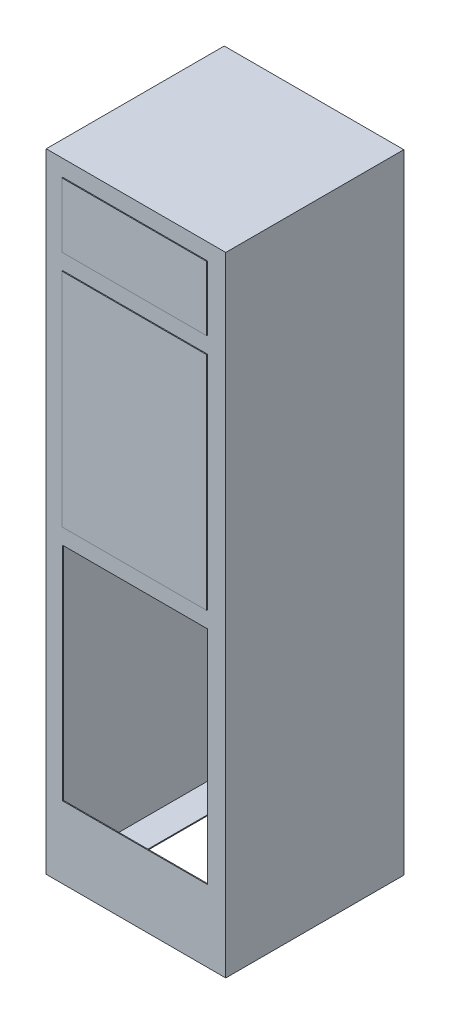
from build123d import *

# Parameters (mm, degrees)
CROQUIS1_W                = 600
CROQUIS1_H                = 2100
SALIENTE_EXTRUIR1_DEPTH   = 595
CROQUIS2_W                = 594
CROQUIS2_H                = 2094
CORTAR_EXTRUIR1_DEPTH     = 592
CROQUIS3_W                = 594
CROQUIS3_H                = 237
SALIENTE_EXTRUIR2_DEPTH   = 3
CROQUIS4_W                = 400
CROQUIS4_H                = 395
CORTAR_EXTRUIR2_DEPTH     = 3
CROQUIS5_W                = 52
CROQUIS5_H                = 740
SALIENTE_EXTRUIR3_DEPTH   = 3
CROQUIS5_W_2              = 58
SALIENTE_EXTRUIR3_2_DEPTH = 3
CROQUIS6_W                = 484
CROQUIS6_H                = 740
SALIENTE_EXTRUIR4_DEPTH   = 3
CROQUIS7_W                = 594
CROQUIS7_H                = 55
SALIENTE_EXTRUIR5_DEPTH   = 3
CROQUIS8_W                = 52
CROQUIS8_H                = 740
CROQUIS8_W_2              = 58
SALIENTE_EXTRUIR6_DEPTH   = 3
CROQUIS9_W                = 484
CROQUIS9_H                = 740
SALIENTE_EXTRUIR7_DEPTH   = 3
CROQUIS10_W               = 594
CROQUIS10_H               = 322
CROQUIS10_W_2             = 484
CROQUIS10_H_2             = 215
SALIENTE_EXTRUIR8_DEPTH   = 3
CROQUIS11_W               = 484
CROQUIS11_H               = 215
SALIENTE_EXTRUIR9_DEPTH   = 3
CROQUIS12_W               = 484
CROQUIS12_H               = 740
CORTAR_EXTRUIR3_DEPTH     = 4


with BuildPart() as part:
    # Croquis1 → Saliente-Extruir1 (new body)
    with BuildSketch(Plane.XY):
        Rectangle(CROQUIS1_W, CROQUIS1_H)
    extrude(amount=SALIENTE_EXTRUIR1_DEPTH)

    # Croquis2 → Cortar-Extruir1 (cut)
    with BuildSketch(Plane.XY.offset(595)):
        Rectangle(CROQUIS2_W, CROQUIS2_H)
    extrude(amount=-CORTAR_EXTRUIR1_DEPTH, mode=Mode.SUBTRACT)

    # Croquis3 → Saliente-Extruir2 (add)
    with BuildSketch(Plane.XY.offset(595)):
        with Locations((0, -928.5)):
            Rectangle(CROQUIS3_W, CROQUIS3_H)
    extrude(amount=-SALIENTE_EXTRUIR2_DEPTH)

    # Croquis4 → Cortar-Extruir2 (cut)
    with BuildSketch(Plane.XZ.offset(1050)):
        with Locations((0, 297.5)):
            Rectangle(CROQUIS4_W, CROQUIS4_H)
    extrude(amount=-CORTAR_EXTRUIR2_DEPTH, mode=Mode.SUBTRACT)



with BuildPart() as body_2:
    # Croquis5 → Saliente-Extruir3 (new body)
    with BuildSketch(Plane.XY.offset(595)):
        with Locations((-271, -440)):
            Rectangle(CROQUIS5_W, CROQUIS5_H)
    extrude(amount=-SALIENTE_EXTRUIR3_DEPTH)


with BuildPart() as body_3:
    # Croquis5 → Saliente-Extruir3 2 (new body)
    with BuildSketch(Plane.XY.offset(595)):
        with Locations((268, -440)):
            Rectangle(CROQUIS5_W_2, CROQUIS5_H)
    extrude(amount=-SALIENTE_EXTRUIR3_2_DEPTH)


with BuildPart() as part_1:
    add(part.part)

    add(body_2.part)  # Saliente-Extruir4 merges body 2

    add(body_3.part)  # Saliente-Extruir4 merges body 3
    # Croquis6 → Saliente-Extruir4 (add)
    with BuildSketch(Plane.XY.offset(595)):
        with Locations((-3, -440)):
            Rectangle(CROQUIS6_W, CROQUIS6_H)
    extrude(amount=SALIENTE_EXTRUIR4_DEPTH)

    # Croquis7 → Saliente-Extruir5 (add)
    with BuildSketch(Plane.XY.offset(595)):
        with Locations((0, -42.5)):
            Rectangle(CROQUIS7_W, CROQUIS7_H)
    extrude(amount=-SALIENTE_EXTRUIR5_DEPTH)

    # Croquis8 → Saliente-Extruir6 (add)
    with BuildSketch(Plane.XY.offset(595)):
        with Locations((-271, 355)):
            Rectangle(CROQUIS8_W, CROQUIS8_H)
        with Locations((268, 355)):
            Rectangle(CROQUIS8_W_2, CROQUIS8_H)
    extrude(amount=-SALIENTE_EXTRUIR6_DEPTH)



with BuildPart() as body_2_2:
    # Croquis9 → Saliente-Extruir7 (new body)
    with BuildSketch(Plane.XY.offset(595)):
        with Locations((-3, 355)):
            Rectangle(CROQUIS9_W, CROQUIS9_H)
    extrude(amount=SALIENTE_EXTRUIR7_DEPTH)


with BuildPart() as part_2:
    add(part_1.part)

    add(body_2_2.part)  # Saliente-Extruir8 merges body 2 2
    # Croquis10 → Saliente-Extruir8 (add)
    with BuildSketch(Plane.XY.offset(595)):
        with Locations((0, 886)):
            Rectangle(CROQUIS10_W, CROQUIS10_H)
        with Locations((-3, 887.5)):
            Rectangle(CROQUIS10_W_2, CROQUIS10_H_2, mode=Mode.SUBTRACT)
    extrude(amount=-SALIENTE_EXTRUIR8_DEPTH)

    # Croquis12 → Cortar-Extruir3 (cut)
    with BuildSketch(Plane.XY.offset(598)):
        with Locations((-3, -440)):
            Rectangle(CROQUIS12_W, CROQUIS12_H)
    extrude(amount=-CORTAR_EXTRUIR3_DEPTH, mode=Mode.SUBTRACT)


with BuildPart() as body_2_3:
    # Croquis11 → Saliente-Extruir9 (new body)
    with BuildSketch(Plane.XY.offset(595)):
        with Locations((-3, 887.5)):
            Rectangle(CROQUIS11_W, CROQUIS11_H)
    extrude(amount=SALIENTE_EXTRUIR9_DEPTH)


solid = Compound([part_2.part, body_2_3.part])
